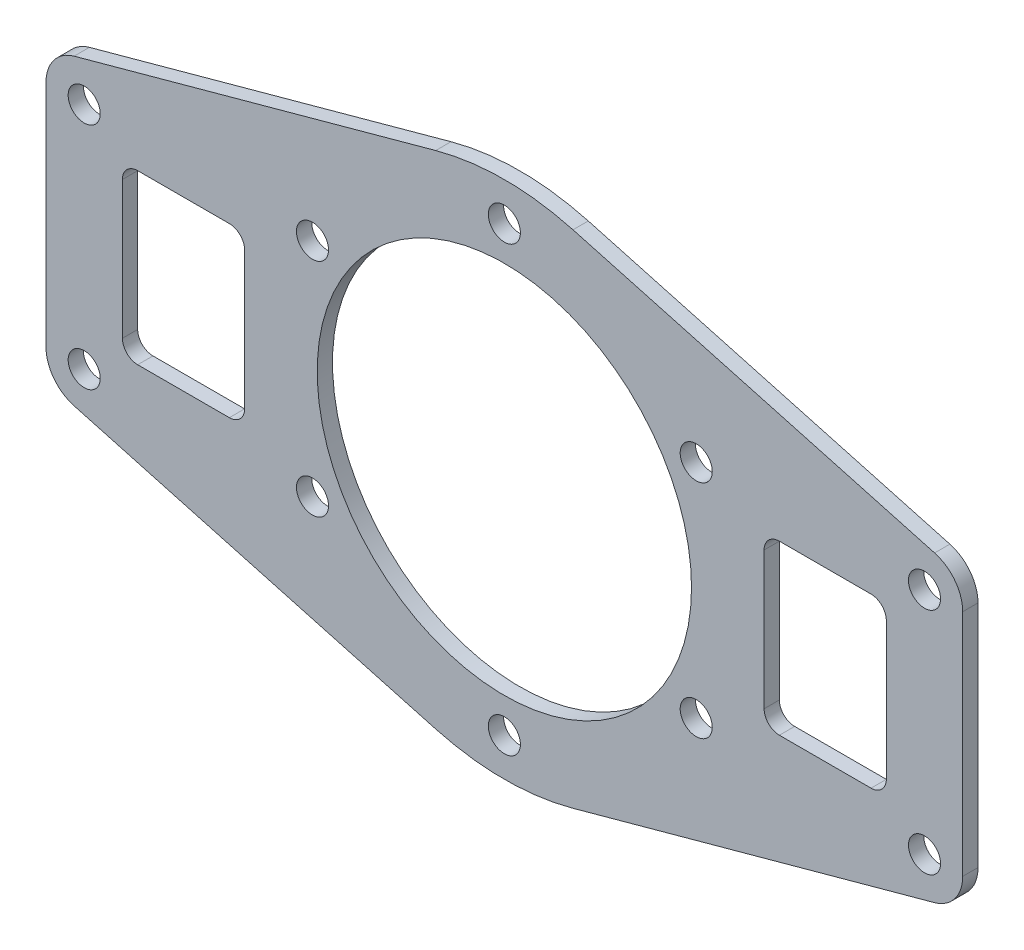
from build123d import *

# Parameters (mm, degrees)
SKETCH_1_R          = 24.5
SKETCH_1_R_2        = 2.1
EXTRUDE_1_DEPTH     = 2
CUT_EXTRUDE_1_DEPTH = 10


with BuildPart() as part:
    # 草图1 → 凸台-拉伸1 (new body)
    with BuildSketch(Plane.XY):
        with BuildLine():
            Line((-60, 15), (-60, -15))
            ThreePointArc((-60, -15), (-58.975297052, -18.032657803), (-56.321194659, -19.82228625))
            Line((-56.321194659, -19.82228625), (-8.984123683, -32.791546497))
            ThreePointArc((-8.984123683, -32.791546497), (0, -34), (8.984123683, -32.791546497))
            Line((8.984123683, -32.791546497), (56.321194659, -19.82228625))
            ThreePointArc((56.321194659, -19.82228625), (58.975297052, -18.032657803), (60, -15))
            Line((60, -15), (60, 15))
            ThreePointArc((60, 15), (58.975297052, 18.032657803), (56.321194659, 19.82228625))
            Line((56.321194659, 19.82228625), (8.984123683, 32.791546497))
            ThreePointArc((8.984123683, 32.791546497), (0, 34), (-8.984123683, 32.791546497))
            Line((-8.984123683, 32.791546497), (-56.321194659, 19.82228625))
            ThreePointArc((-56.321194659, 19.82228625), (-58.975297052, 18.032657803), (-60, 15))
        make_face()
        Circle(SKETCH_1_R, mode=Mode.SUBTRACT)
        with Locations((0, 29)):
            Circle(SKETCH_1_R_2, mode=Mode.SUBTRACT)
        with Locations((25.11473671, 14.5)):
            Circle(SKETCH_1_R_2, mode=Mode.SUBTRACT)
        with Locations((25.11473671, -14.5)):
            Circle(SKETCH_1_R_2, mode=Mode.SUBTRACT)
        with Locations((0, -29)):
            Circle(SKETCH_1_R_2, mode=Mode.SUBTRACT)
        with Locations((-25.11473671, -14.5)):
            Circle(SKETCH_1_R_2, mode=Mode.SUBTRACT)
        with Locations((-25.11473671, 14.5)):
            Circle(SKETCH_1_R_2, mode=Mode.SUBTRACT)
        with Locations((-55, 15)):
            Circle(SKETCH_1_R_2, mode=Mode.SUBTRACT)
        with Locations((-55, -15)):
            Circle(SKETCH_1_R_2, mode=Mode.SUBTRACT)
        with Locations((55, -15)):
            Circle(SKETCH_1_R_2, mode=Mode.SUBTRACT)
        with Locations((55, 15)):
            Circle(SKETCH_1_R_2, mode=Mode.SUBTRACT)
    extrude(amount=EXTRUDE_1_DEPTH)

    # 草图2 → 切除-拉伸1 (cut)
    with BuildSketch(Plane.XY.offset(2)):
        with BuildLine():
            Line((-48, 11), (-36, 11))
            ThreePointArc((-36, 11), (-34.585786438, 10.414213562), (-34, 9))
            Line((-34, 9), (-34, -9))
            ThreePointArc((-34, -9), (-34.585786438, -10.414213562), (-36, -11))
            Line((-36, -11), (-48, -11))
            ThreePointArc((-48, -11), (-49.414213562, -10.414213562), (-50, -9))
            Line((-50, -9), (-50, 9))
            ThreePointArc((-50, 9), (-49.414213562, 10.414213562), (-48, 11))
        make_face()
        with BuildLine():
            Line((36, 11), (48, 11))
            ThreePointArc((48, 11), (49.414213562, 10.414213562), (50, 9))
            Line((50, 9), (50, -9))
            ThreePointArc((50, -9), (49.414213562, -10.414213562), (48, -11))
            Line((48, -11), (36, -11))
            ThreePointArc((36, -11), (34.585786438, -10.414213562), (34, -9))
            Line((34, -9), (34, 9))
            ThreePointArc((34, 9), (34.585786438, 10.414213562), (36, 11))
        make_face()
    extrude(amount=-CUT_EXTRUDE_1_DEPTH, mode=Mode.SUBTRACT)


solid = part.part
